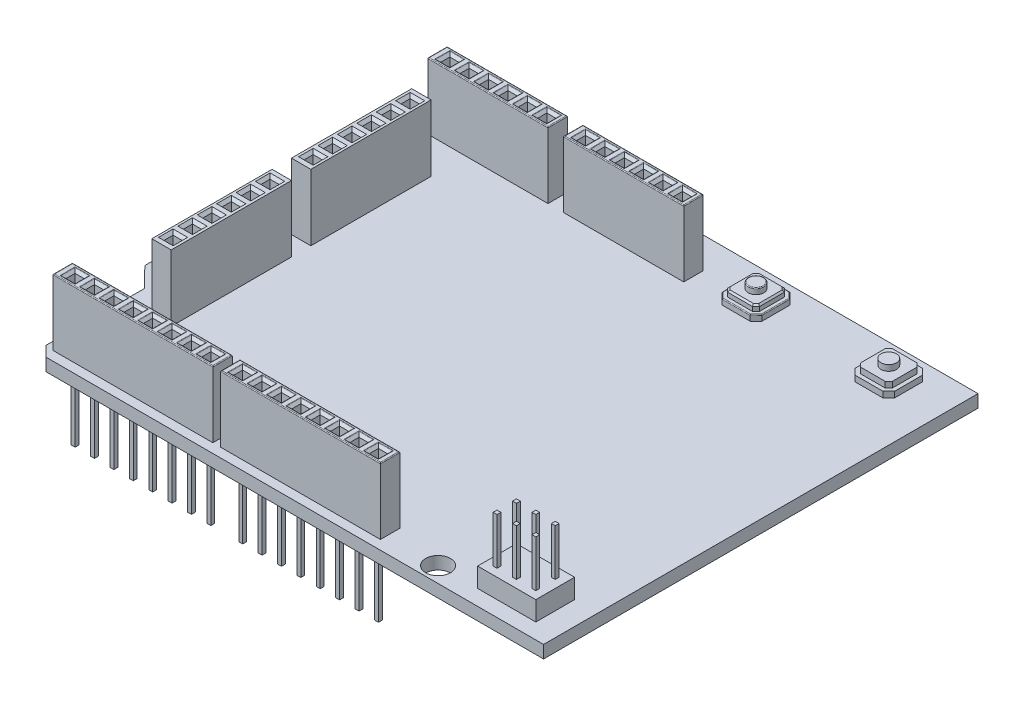
from build123d import *

# Parameters (mm, degrees)
SKETCH1_W            = 68
SKETCH1_H            = 56
BOSS_EXTRUDE1_DEPTH  = 1.63
SKETCH2_W            = 15.5
SKETCH2_H            = 2.5
SKETCH2_W_2          = 20.6
SKETCH2_W_3          = 2.5
SKETCH2_H_2          = 15.5
BOSS_EXTRUDE2_DEPTH  = 8.54
BOSS_EXTRUDE3_DEPTH  = 0.75
BOSS_EXTRUDE4_DEPTH  = 0.75
SKETCH5_R            = 1
BOSS_EXTRUDE5_DEPTH  = 0.75
CHAMFER1_SIZE        = 0.2
FILLET1_R            = 0.1
FILLET2_R            = 0.1
SKETCH7_W            = 1.18
SKETCH7_H            = 1.18
CUT_EXTRUDE1_DEPTH   = 6.58
CHAMFER3_SIZE        = 0.35
CUT_EXTRUDE2_DEPTH   = 2.63
CHAMFER5_SIZE        = 1.32
SKETCH11_W           = 0.5
SKETCH11_H           = 0.5
BOSS_EXTRUDE8_DEPTH  = 8.75
FILLET5_R            = 0.1
SKETCH12_R           = 1.6
CUT_EXTRUDE4_DEPTH   = 11.38
SKETCH18_W           = 7.5
SKETCH18_H           = 5
BOSS_EXTRUDE9_DEPTH  = 2.5
SKETCH19_W           = 0.5
SKETCH19_H           = 0.5
BOSS_EXTRUDE10_DEPTH = 6
LPATTERN6_COUNT      = 2
LPATTERN6_PITCH      = 2.5
LPATTERN6_COUNT_DIR2 = 3
LPATTERN6_PITCH_DIR2 = 2.5


with BuildPart() as part:
    # Sketch1 → Boss-Extrude1 (new body)
    with BuildSketch(Plane(origin=(0, 0, 0), x_dir=(1, 0, 0), z_dir=(0, 1, 0))):
        Rectangle(SKETCH1_W, SKETCH1_H)
    extrude(amount=BOSS_EXTRUDE1_DEPTH)

    # Sketch2 → Boss-Extrude2 (add)
    with BuildSketch(Plane(origin=(0, 1.63, 0), x_dir=(1, 0, 0), z_dir=(0, 1, 0))):
        with Locations((-22.68, 22.75)):
            Rectangle(SKETCH2_W, SKETCH2_H)
        with Locations((-5.18, 22.75)):
            Rectangle(SKETCH2_W, SKETCH2_H)
        with Locations((1.47, -25.55)):
            Rectangle(SKETCH2_W_2, SKETCH2_H)
        with Locations((-20.13, -25.55)):
            Rectangle(SKETCH2_W_2, SKETCH2_H)
        with Locations((-26.75, 9.25)):
            Rectangle(SKETCH2_W_3, SKETCH2_H_2)
        with Locations((-26.75, -8.75)):
            Rectangle(SKETCH2_W_3, SKETCH2_H_2)
    extrude(amount=BOSS_EXTRUDE2_DEPTH)

    # Sketch3 → Boss-Extrude3 (add)
    with BuildSketch(Plane(origin=(0, 1.63, 0), x_dir=(1, 0, 0), z_dir=(0, 1, 0))):
        Polygon((7.64, 26.5), (11.25, 26.5), (12, 25.75), (12, 22.14), (11.25, 21.39), (7.64, 21.39), (6.89, 22.14), (6.89, 25.75), align=None)
    boss_extrude3 = extrude(amount=BOSS_EXTRUDE3_DEPTH)

    # Sketch4 → Boss-Extrude4 (add)
    with BuildSketch(Plane(origin=(0, 2.38, 0), x_dir=(1, 0, 0), z_dir=(0, 1, 0))):
        Polygon((7.39, 22.347106781), (7.847106781, 21.89), (11.042893219, 21.89), (11.5, 22.347106781), (11.5, 25.542893219), (11.042893219, 26), (7.847106781, 26), (7.39, 25.542893219), align=None)
    boss_extrude4 = extrude(amount=BOSS_EXTRUDE4_DEPTH)

    # Sketch5 → Boss-Extrude5 (add)
    with BuildSketch(Plane(origin=(0, 3.13, 0), x_dir=(1, 0, 0), z_dir=(0, 1, 0))):
        with Locations((9.445, 23.945)):
            Circle(SKETCH5_R)
    boss_extrude5 = extrude(amount=BOSS_EXTRUDE5_DEPTH)

    # Chamfer1
    chamfer1_edges = [part.edges().sort_by_distance(p)[0] for p in [
        (11.271446609, 3.13, -25.771446609),
        (9.445, 3.13, -26),
        (7.618553391, 3.13, -25.771446609),
        (7.39, 3.13, -23.945),
        (7.618553391, 3.13, -22.118553391),
        (9.445, 3.13, -21.89),
        (11.271446609, 3.13, -22.118553391),
        (11.5, 3.13, -23.945),
    ]]
    chamfer(chamfer1_edges, length=CHAMFER1_SIZE)

    # Fillet1
    fillet1_edges = [part.edges().sort_by_distance(p)[0] for p in [
        (8.445, 3.88, -23.945),
    ]]
    fillet(fillet1_edges, radius=FILLET1_R)

    # Fillet2
    fillet2_edges = [part.edges().sort_by_distance(p)[0] for p in [
        (11.625, 2.38, -26.125),
        (9.445, 2.38, -26.5),
        (7.265, 2.38, -26.125),
        (6.89, 2.38, -23.945),
        (7.265, 2.38, -21.765),
        (9.445, 2.38, -21.39),
        (11.625, 2.38, -21.765),
        (12, 2.38, -23.945),
    ]]
    fillet(fillet2_edges, radius=FILLET2_R)

    # Sketch7 → Cut-Extrude1 (cut)
    with BuildSketch(Plane(origin=(0, 10.17, 0), x_dir=(1, 0, 0), z_dir=(0, 1, 0))):
        with Locations((-28.84, 22.75)):
            Rectangle(SKETCH7_W, SKETCH7_H)
        with Locations((-26.34, 22.75)):
            Rectangle(SKETCH7_W, SKETCH7_H)
        with Locations((-23.84, 22.75)):
            Rectangle(SKETCH7_W, SKETCH7_H)
        with Locations((-21.34, 22.75)):
            Rectangle(SKETCH7_W, SKETCH7_H)
        with Locations((-18.84, 22.75)):
            Rectangle(SKETCH7_W, SKETCH7_H)
        with Locations((-16.34, 22.75)):
            Rectangle(SKETCH7_W, SKETCH7_H)
        with Locations((-28.84, -25.55)):
            Rectangle(SKETCH7_W, SKETCH7_H)
        with Locations((-11.34, 22.75)):
            Rectangle(SKETCH7_W, SKETCH7_H)
        with Locations((-8.84, 22.75)):
            Rectangle(SKETCH7_W, SKETCH7_H)
        with Locations((-6.34, 22.75)):
            Rectangle(SKETCH7_W, SKETCH7_H)
        with Locations((-3.84, 22.75)):
            Rectangle(SKETCH7_W, SKETCH7_H)
        with Locations((-1.34, 22.75)):
            Rectangle(SKETCH7_W, SKETCH7_H)
        with Locations((1.16, 22.75)):
            Rectangle(SKETCH7_W, SKETCH7_H)
        with Locations((-26.34, -25.55)):
            Rectangle(SKETCH7_W, SKETCH7_H)
        with Locations((-23.84, -25.55)):
            Rectangle(SKETCH7_W, SKETCH7_H)
        with Locations((-21.34, -25.55)):
            Rectangle(SKETCH7_W, SKETCH7_H)
        with Locations((-18.84, -25.55)):
            Rectangle(SKETCH7_W, SKETCH7_H)
        with Locations((-16.34, -25.55)):
            Rectangle(SKETCH7_W, SKETCH7_H)
        with Locations((-13.84, -25.55)):
            Rectangle(SKETCH7_W, SKETCH7_H)
        with Locations((-11.34, -25.55)):
            Rectangle(SKETCH7_W, SKETCH7_H)
        with Locations((-7.24, -25.55)):
            Rectangle(SKETCH7_W, SKETCH7_H)
        with Locations((-4.74, -25.55)):
            Rectangle(SKETCH7_W, SKETCH7_H)
        with Locations((-2.24, -25.55)):
            Rectangle(SKETCH7_W, SKETCH7_H)
        with Locations((0.26, -25.55)):
            Rectangle(SKETCH7_W, SKETCH7_H)
        with Locations((2.76, -25.55)):
            Rectangle(SKETCH7_W, SKETCH7_H)
        with Locations((5.26, -25.55)):
            Rectangle(SKETCH7_W, SKETCH7_H)
        with Locations((7.76, -25.55)):
            Rectangle(SKETCH7_W, SKETCH7_H)
        with Locations((10.26, -25.55)):
            Rectangle(SKETCH7_W, SKETCH7_H)
        with Locations((-26.748603854, 15.551491297)):
            Rectangle(SKETCH7_W, SKETCH7_H)
        with Locations((-26.748603854, 13.051491297)):
            Rectangle(SKETCH7_W, SKETCH7_H)
        with Locations((-26.748603854, 10.551491297)):
            Rectangle(SKETCH7_W, SKETCH7_H)
        with Locations((-26.748603854, 8.051491297)):
            Rectangle(SKETCH7_W, SKETCH7_H)
        with Locations((-26.748603854, 5.551491297)):
            Rectangle(SKETCH7_W, SKETCH7_H)
        with Locations((-26.748603854, 3.051491297)):
            Rectangle(SKETCH7_W, SKETCH7_H)
        with Locations((-26.783884438, -2.474589496)):
            Rectangle(SKETCH7_W, SKETCH7_H)
        with Locations((-26.783884438, -4.974589496)):
            Rectangle(SKETCH7_W, SKETCH7_H)
        with Locations((-26.783884438, -7.474589496)):
            Rectangle(SKETCH7_W, SKETCH7_H)
        with Locations((-26.783884438, -9.974589496)):
            Rectangle(SKETCH7_W, SKETCH7_H)
        with Locations((-26.783884438, -12.474589496)):
            Rectangle(SKETCH7_W, SKETCH7_H)
        with Locations((-26.783884438, -14.974589496)):
            Rectangle(SKETCH7_W, SKETCH7_H)
    extrude(amount=-CUT_EXTRUDE1_DEPTH, mode=Mode.SUBTRACT)

    # Chamfer3
    chamfer3_edges = [part.edges().sort_by_distance(p)[0] for p in [
        (-28.25, 10.17, -22.75),
        (-28.84, 10.17, -23.34),
        (-29.43, 10.17, -22.75),
        (-28.84, 10.17, -22.16),
        (-28.25, 10.17, 25.55),
        (-28.84, 10.17, 24.96),
        (-29.43, 10.17, 25.55),
        (-28.84, 10.17, 26.14),
        (-26.34, 10.17, -22.16),
        (-25.75, 10.17, -22.75),
        (-26.34, 10.17, -23.34),
        (-26.93, 10.17, -22.75),
        (-23.84, 10.17, -22.16),
        (-23.25, 10.17, -22.75),
        (-23.84, 10.17, -23.34),
        (-24.43, 10.17, -22.75),
        (-21.34, 10.17, -22.16),
        (-20.75, 10.17, -22.75),
        (-21.34, 10.17, -23.34),
        (-21.93, 10.17, -22.75),
        (-18.84, 10.17, -22.16),
        (-18.25, 10.17, -22.75),
        (-18.84, 10.17, -23.34),
        (-19.43, 10.17, -22.75),
        (-16.34, 10.17, -22.16),
        (-15.75, 10.17, -22.75),
        (-16.34, 10.17, -23.34),
        (-16.93, 10.17, -22.75),
        (-11.34, 10.17, -22.16),
        (-10.75, 10.17, -22.75),
        (-11.34, 10.17, -23.34),
        (-11.93, 10.17, -22.75),
        (-8.84, 10.17, -22.16),
        (-8.25, 10.17, -22.75),
        (-8.84, 10.17, -23.34),
        (-9.43, 10.17, -22.75),
        (-6.34, 10.17, -22.16),
        (-5.75, 10.17, -22.75),
        (-6.34, 10.17, -23.34),
        (-6.93, 10.17, -22.75),
        (-3.84, 10.17, -22.16),
        (-3.25, 10.17, -22.75),
        (-3.84, 10.17, -23.34),
        (-4.43, 10.17, -22.75),
        (-1.34, 10.17, -22.16),
        (-0.75, 10.17, -22.75),
        (-1.34, 10.17, -23.34),
        (-1.93, 10.17, -22.75),
        (1.16, 10.17, -22.16),
        (1.75, 10.17, -22.75),
        (1.16, 10.17, -23.34),
        (0.57, 10.17, -22.75),
        (-6.65, 10.17, 25.55),
        (-7.24, 10.17, 24.96),
        (-7.83, 10.17, 25.55),
        (-7.24, 10.17, 26.14),
        (-26.34, 10.17, 26.14),
        (-25.75, 10.17, 25.55),
        (-26.34, 10.17, 24.96),
        (-26.93, 10.17, 25.55),
        (-23.84, 10.17, 26.14),
        (-23.25, 10.17, 25.55),
        (-23.84, 10.17, 24.96),
        (-24.43, 10.17, 25.55),
        (-21.34, 10.17, 26.14),
        (-20.75, 10.17, 25.55),
        (-21.34, 10.17, 24.96),
        (-21.93, 10.17, 25.55),
        (-18.84, 10.17, 26.14),
        (-18.25, 10.17, 25.55),
        (-18.84, 10.17, 24.96),
        (-19.43, 10.17, 25.55),
        (-16.34, 10.17, 26.14),
        (-15.75, 10.17, 25.55),
        (-16.34, 10.17, 24.96),
        (-16.93, 10.17, 25.55),
        (-13.84, 10.17, 26.14),
        (-13.25, 10.17, 25.55),
        (-13.84, 10.17, 24.96),
        (-14.43, 10.17, 25.55),
        (-11.34, 10.17, 26.14),
        (-10.75, 10.17, 25.55),
        (-11.34, 10.17, 24.96),
        (-11.93, 10.17, 25.55),
        (-27.338603854, 10.17, -15.551491297),
        (-26.748603854, 10.17, -14.961491297),
        (-26.158603854, 10.17, -15.551491297),
        (-26.748603854, 10.17, -16.141491297),
        (-4.74, 10.17, 26.14),
        (-4.15, 10.17, 25.55),
        (-4.74, 10.17, 24.96),
        (-5.33, 10.17, 25.55),
        (-2.24, 10.17, 26.14),
        (-1.65, 10.17, 25.55),
        (-2.24, 10.17, 24.96),
        (-2.83, 10.17, 25.55),
        (0.26, 10.17, 26.14),
        (0.85, 10.17, 25.55),
        (0.26, 10.17, 24.96),
        (-0.33, 10.17, 25.55),
        (2.76, 10.17, 26.14),
        (3.35, 10.17, 25.55),
        (2.76, 10.17, 24.96),
        (2.17, 10.17, 25.55),
        (5.26, 10.17, 26.14),
        (5.85, 10.17, 25.55),
        (5.26, 10.17, 24.96),
        (4.67, 10.17, 25.55),
        (7.76, 10.17, 26.14),
        (8.35, 10.17, 25.55),
        (7.76, 10.17, 24.96),
        (7.17, 10.17, 25.55),
        (10.26, 10.17, 26.14),
        (10.85, 10.17, 25.55),
        (10.26, 10.17, 24.96),
        (9.67, 10.17, 25.55),
        (-27.338603854, 10.17, -13.051491297),
        (-26.748603854, 10.17, -12.461491297),
        (-26.158603854, 10.17, -13.051491297),
        (-26.748603854, 10.17, -13.641491297),
        (-27.338603854, 10.17, -10.551491297),
        (-26.748603854, 10.17, -9.961491297),
        (-26.158603854, 10.17, -10.551491297),
        (-26.748603854, 10.17, -11.141491297),
        (-27.338603854, 10.17, -8.051491297),
        (-26.748603854, 10.17, -7.461491297),
        (-26.158603854, 10.17, -8.051491297),
        (-26.748603854, 10.17, -8.641491297),
        (-27.338603854, 10.17, -5.551491297),
        (-26.748603854, 10.17, -4.961491297),
        (-26.158603854, 10.17, -5.551491297),
        (-26.748603854, 10.17, -6.141491297),
        (-27.338603854, 10.17, -3.051491297),
        (-26.748603854, 10.17, -2.461491297),
        (-26.158603854, 10.17, -3.051491297),
        (-26.748603854, 10.17, -3.641491297),
        (-27.373884438, 10.17, 2.474589496),
        (-26.783884438, 10.17, 3.064589496),
        (-26.193884438, 10.17, 2.474589496),
        (-26.783884438, 10.17, 1.884589496),
        (-27.373884438, 10.17, 4.974589496),
        (-26.783884438, 10.17, 5.564589496),
        (-26.193884438, 10.17, 4.974589496),
        (-26.783884438, 10.17, 4.384589496),
        (-27.373884438, 10.17, 7.474589496),
        (-26.783884438, 10.17, 8.064589496),
        (-26.193884438, 10.17, 7.474589496),
        (-26.783884438, 10.17, 6.884589496),
        (-27.373884438, 10.17, 9.974589496),
        (-26.783884438, 10.17, 10.564589496),
        (-26.193884438, 10.17, 9.974589496),
        (-26.783884438, 10.17, 9.384589496),
        (-27.373884438, 10.17, 12.474589496),
        (-26.783884438, 10.17, 13.064589496),
        (-26.193884438, 10.17, 12.474589496),
        (-26.783884438, 10.17, 11.884589496),
        (-27.373884438, 10.17, 14.974589496),
        (-26.783884438, 10.17, 15.564589496),
        (-26.193884438, 10.17, 14.974589496),
        (-26.783884438, 10.17, 14.384589496),
    ]]
    chamfer(chamfer3_edges, length=CHAMFER3_SIZE)

    # Sketch8 → Cut-Extrude2 (cut, through all)
    with BuildSketch(Plane(origin=(0, 1.63, 0), x_dir=(1, 0, 0), z_dir=(0, 1, 0))):
        Polygon((-31.46, 28), (-31.46, 24.34), (-34, 21.3), (-34, 28), align=None)
        Polygon((-31.46, -14), (-31.46, -28), (-34, -28), (-34, -11.4), align=None)
    extrude(amount=-CUT_EXTRUDE2_DEPTH, mode=Mode.SUBTRACT)

    # Chamfer5
    chamfer5_edges = [part.edges().sort_by_distance(p)[0] for p in [
        (-31.46, 0.815, 28),
    ]]
    chamfer(chamfer5_edges, length=CHAMFER5_SIZE)

    # Sketch11 → Boss-Extrude8 (add)
    with BuildSketch(Plane.XZ):
        with Locations((-26.34, 25.55)):
            Rectangle(SKETCH11_W, SKETCH11_H)
        with Locations((-28.84, 25.55)):
            Rectangle(SKETCH11_W, SKETCH11_H)
        with Locations((-23.84, 25.55)):
            Rectangle(SKETCH11_W, SKETCH11_H)
        with Locations((-21.34, 25.55)):
            Rectangle(SKETCH11_W, SKETCH11_H)
        with Locations((-18.84, 25.55)):
            Rectangle(SKETCH11_W, SKETCH11_H)
        with Locations((-16.34, 25.55)):
            Rectangle(SKETCH11_W, SKETCH11_H)
        with Locations((-13.84, 25.55)):
            Rectangle(SKETCH11_W, SKETCH11_H)
        with Locations((-11.34, 25.55)):
            Rectangle(SKETCH11_W, SKETCH11_H)
        with Locations((-4.74, 25.55)):
            Rectangle(SKETCH11_W, SKETCH11_H)
        with Locations((-7.24, 25.55)):
            Rectangle(SKETCH11_W, SKETCH11_H)
        with Locations((-2.24, 25.55)):
            Rectangle(SKETCH11_W, SKETCH11_H)
        with Locations((0.26, 25.55)):
            Rectangle(SKETCH11_W, SKETCH11_H)
        with Locations((2.76, 25.55)):
            Rectangle(SKETCH11_W, SKETCH11_H)
        with Locations((5.26, 25.55)):
            Rectangle(SKETCH11_W, SKETCH11_H)
        with Locations((7.76, 25.55)):
            Rectangle(SKETCH11_W, SKETCH11_H)
        with Locations((10.26, 25.55)):
            Rectangle(SKETCH11_W, SKETCH11_H)
        with Locations((-26.34, -22.75)):
            Rectangle(SKETCH11_W, SKETCH11_H)
        with Locations((-28.84, -22.75)):
            Rectangle(SKETCH11_W, SKETCH11_H)
        with Locations((-23.84, -22.75)):
            Rectangle(SKETCH11_W, SKETCH11_H)
        with Locations((-21.34, -22.75)):
            Rectangle(SKETCH11_W, SKETCH11_H)
        with Locations((-18.84, -22.75)):
            Rectangle(SKETCH11_W, SKETCH11_H)
        with Locations((-16.34, -22.75)):
            Rectangle(SKETCH11_W, SKETCH11_H)
        with Locations((-11.34, -22.75)):
            Rectangle(SKETCH11_W, SKETCH11_H)
        with Locations((-8.84, -22.75)):
            Rectangle(SKETCH11_W, SKETCH11_H)
        with Locations((-6.34, -22.75)):
            Rectangle(SKETCH11_W, SKETCH11_H)
        with Locations((-3.84, -22.75)):
            Rectangle(SKETCH11_W, SKETCH11_H)
        with Locations((-1.34, -22.75)):
            Rectangle(SKETCH11_W, SKETCH11_H)
        with Locations((1.16, -22.75)):
            Rectangle(SKETCH11_W, SKETCH11_H)
    extrude(amount=BOSS_EXTRUDE8_DEPTH)

    # Fillet5
    fillet5_edges = [part.edges().sort_by_distance(p)[0] for p in [
        (-14.93, 10.17, -22.75),
        (-22.68, 10.17, -24),
        (-30.43, 10.17, -22.75),
        (-22.68, 10.17, -21.5),
        (-9.83, 10.17, 25.55),
        (-20.13, 10.17, 24.3),
        (-30.43, 10.17, 25.55),
        (-20.13, 10.17, 26.8),
        (-5.18, 10.17, -21.5),
        (2.57, 10.17, -22.75),
        (-5.18, 10.17, -24),
        (-12.93, 10.17, -22.75),
        (1.47, 10.17, 26.8),
        (11.77, 10.17, 25.55),
        (1.47, 10.17, 24.3),
        (-8.83, 10.17, 25.55),
        (-7.24, 10.17, 24.61),
        (-8.18, 10.17, 25.55),
        (-6.3, 10.17, 25.55),
        (-7.24, 10.17, 26.49),
        (-4.74, 10.17, 24.61),
        (-5.68, 10.17, 25.55),
        (-3.8, 10.17, 25.55),
        (-4.74, 10.17, 26.49),
        (-2.24, 10.17, 24.61),
        (-3.18, 10.17, 25.55),
        (-1.3, 10.17, 25.55),
        (-2.24, 10.17, 26.49),
        (0.26, 10.17, 24.61),
        (-0.68, 10.17, 25.55),
        (1.2, 10.17, 25.55),
        (0.26, 10.17, 26.49),
        (2.76, 10.17, 24.61),
        (1.82, 10.17, 25.55),
        (3.7, 10.17, 25.55),
        (2.76, 10.17, 26.49),
        (5.26, 10.17, 24.61),
        (4.32, 10.17, 25.55),
        (6.2, 10.17, 25.55),
        (5.26, 10.17, 26.49),
        (7.76, 10.17, 24.61),
        (6.82, 10.17, 25.55),
        (8.7, 10.17, 25.55),
        (7.76, 10.17, 26.49),
        (10.26, 10.17, 24.61),
        (9.32, 10.17, 25.55),
        (11.2, 10.17, 25.55),
        (10.26, 10.17, 26.49),
        (-28.84, 10.17, 24.61),
        (-27.9, 10.17, 25.55),
        (-29.78, 10.17, 25.55),
        (-28.84, 10.17, 26.49),
        (-26.34, 10.17, 24.61),
        (-25.4, 10.17, 25.55),
        (-27.28, 10.17, 25.55),
        (-26.34, 10.17, 26.49),
        (-23.84, 10.17, 24.61),
        (-22.9, 10.17, 25.55),
        (-24.78, 10.17, 25.55),
        (-23.84, 10.17, 26.49),
        (-21.34, 10.17, 24.61),
        (-20.4, 10.17, 25.55),
        (-22.28, 10.17, 25.55),
        (-21.34, 10.17, 26.49),
        (-18.84, 10.17, 24.61),
        (-17.9, 10.17, 25.55),
        (-19.78, 10.17, 25.55),
        (-18.84, 10.17, 26.49),
        (-16.34, 10.17, 24.61),
        (-15.4, 10.17, 25.55),
        (-17.28, 10.17, 25.55),
        (-16.34, 10.17, 26.49),
        (-13.84, 10.17, 24.61),
        (-12.9, 10.17, 25.55),
        (-14.78, 10.17, 25.55),
        (-13.84, 10.17, 26.49),
        (-11.34, 10.17, 24.61),
        (-10.4, 10.17, 25.55),
        (-12.28, 10.17, 25.55),
        (-11.34, 10.17, 26.49),
        (-11.34, 10.17, -21.81),
        (-10.4, 10.17, -22.75),
        (-12.28, 10.17, -22.75),
        (-11.34, 10.17, -23.69),
        (-8.84, 10.17, -21.81),
        (-7.9, 10.17, -22.75),
        (-9.78, 10.17, -22.75),
        (-8.84, 10.17, -23.69),
        (-6.34, 10.17, -21.81),
        (-5.4, 10.17, -22.75),
        (-7.28, 10.17, -22.75),
        (-6.34, 10.17, -23.69),
        (-3.84, 10.17, -21.81),
        (-2.9, 10.17, -22.75),
        (-4.78, 10.17, -22.75),
        (-3.84, 10.17, -23.69),
        (-1.34, 10.17, -21.81),
        (-0.4, 10.17, -22.75),
        (-2.28, 10.17, -22.75),
        (-1.34, 10.17, -23.69),
        (1.16, 10.17, -21.81),
        (2.1, 10.17, -22.75),
        (0.22, 10.17, -22.75),
        (1.16, 10.17, -23.69),
        (-28.84, 10.17, -23.69),
        (-29.78, 10.17, -22.75),
        (-27.9, 10.17, -22.75),
        (-28.84, 10.17, -21.81),
        (-26.34, 10.17, -23.69),
        (-27.28, 10.17, -22.75),
        (-25.4, 10.17, -22.75),
        (-26.34, 10.17, -21.81),
        (-23.84, 10.17, -21.81),
        (-22.9, 10.17, -22.75),
        (-23.84, 10.17, -23.69),
        (-24.78, 10.17, -22.75),
        (-21.34, 10.17, -21.81),
        (-20.4, 10.17, -22.75),
        (-21.34, 10.17, -23.69),
        (-22.28, 10.17, -22.75),
        (-18.84, 10.17, -21.81),
        (-17.9, 10.17, -22.75),
        (-18.84, 10.17, -23.69),
        (-19.78, 10.17, -22.75),
        (-15.4, 10.17, -22.75),
        (-16.34, 10.17, -23.69),
        (-17.28, 10.17, -22.75),
        (-16.34, 10.17, -21.81),
    ]]
    fillet(fillet5_edges, radius=FILLET5_R)

    # Mirror1: Boss-Extrude3, Boss-Extrude4, Boss-Extrude5 across plane
    add(boss_extrude3.mirror(Plane(origin=(18, 0, 0), x_dir=(0, 0, 1), z_dir=(1, 0, 0))))
    add(boss_extrude4.mirror(Plane(origin=(18, 0, 0), x_dir=(0, 0, 1), z_dir=(1, 0, 0))))
    add(boss_extrude5.mirror(Plane(origin=(18, 0, 0), x_dir=(0, 0, 1), z_dir=(1, 0, 0))))

    # Sketch12 → Cut-Extrude4 (cut, through all)
    with BuildSketch(Plane(origin=(0, 1.63, 0), x_dir=(1, 0, 0), z_dir=(0, 1, 0))):
        with Locations((-32, -7.5)):
            Circle(SKETCH12_R)
        with Locations((18.4, -26)):
            Circle(SKETCH12_R)
    extrude(amount=-CUT_EXTRUDE4_DEPTH, mode=Mode.SUBTRACT)

    # Sketch18 → Boss-Extrude9 (add)
    with BuildSketch(Plane(origin=(0, 1.63, 0), x_dir=(1, 0, 0), z_dir=(0, 1, 0))):
        with Locations((27.25, -23.5)):
            Rectangle(SKETCH18_W, SKETCH18_H)
    extrude(amount=BOSS_EXTRUDE9_DEPTH)

    # Sketch19 → Boss-Extrude10 (add)
    with BuildSketch(Plane(origin=(0, 4.13, 0), x_dir=(1, 0, 0), z_dir=(0, 1, 0))):
        with Locations((24.75, -22.25)):
            Rectangle(SKETCH19_W, SKETCH19_H)
    boss_extrude10 = extrude(amount=BOSS_EXTRUDE10_DEPTH)

    # LPattern6: Boss-Extrude10 2 × 3
    with Locations(*[(j * LPATTERN6_PITCH_DIR2, 0, i * LPATTERN6_PITCH) for i in range(LPATTERN6_COUNT) for j in range(LPATTERN6_COUNT_DIR2) if (i, j) != (0, 0)]):
        add(boss_extrude10)


solid = part.part
